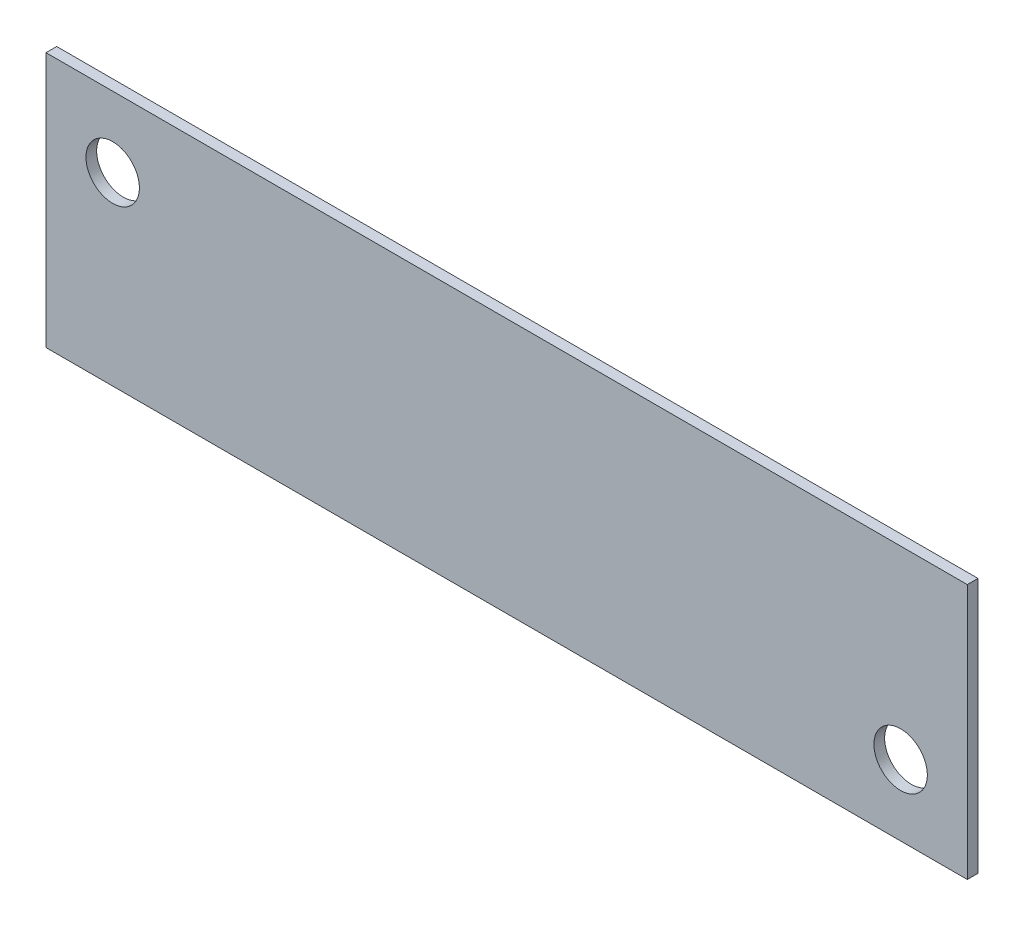
from build123d import *

# Parameters (mm, degrees)
SKETCH1_W           = 273.600000032
SKETCH1_H           = 75.85
BOSS_EXTRUDE1_DEPTH = 3.175
SKETCH2_R           = 7.9375
CUT_EXTRUDE1_DEPTH  = 3.175


with BuildPart() as part:
    # Sketch1 → Boss-Extrude1 (new body)
    with BuildSketch(Plane.XY):
        with Locations((117, 34.75)):
            Rectangle(SKETCH1_W, SKETCH1_H)
    extrude(amount=BOSS_EXTRUDE1_DEPTH)

    # Sketch2 → Cut-Extrude1 (cut)
    with BuildSketch(Plane.XY.offset(3.175)):
        with Locations((0, 51.75)):
            Circle(SKETCH2_R)
        with Locations((234, 17.75)):
            Circle(SKETCH2_R)
    extrude(amount=-CUT_EXTRUDE1_DEPTH, mode=Mode.SUBTRACT)


solid = part.part
